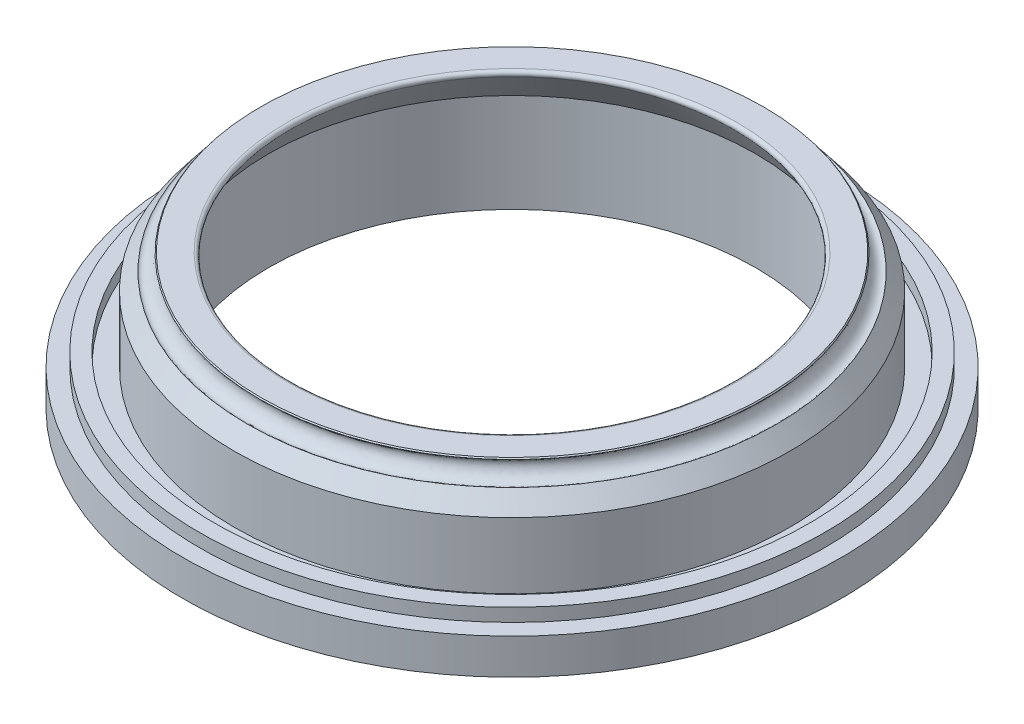
from build123d import *

# Parameters (mm, degrees)
SKETCH2_R          = 2.35
CUT_EXTRUDE2_DEPTH = 5
FILLET1_R          = 1


with BuildPart() as part:
    # Sketch1 → Revolve1 (revolve)
    with BuildSketch(Plane.XY):
        with BuildLine():
            Line((76.326451616, 40.74810371), (66.326451616, 40.74810371))
            Line((66.326451616, 40.74810371), (73.87218168, 29.674663888))
            Line((73.87218168, 29.674663888), (73.87218168, -0.262378674))
            Line((73.87218168, -0.262378674), (75.701423587, -0.262378674))
            add(Edge.make_bspline(
                [(81.701423587, -0.262378674), (81.701423587, 1.737621326), (78.701423587, 1.737621326), (75.701423587, 1.737621326), (75.701423587, -0.262378674)],
                knots=[3.141592654, 3.141592654, 3.141592654, 4.71238898, 4.71238898, 6.283185307, 6.283185307, 6.283185307], degree=2, weights=[1, 0.707106781, 1, 0.707106781, 1]))
            Line((81.701423587, -0.262378674), (100, -0.262378674))
            Line((100, -0.262378674), (100, 10.525760657))
            Line((100, 10.525760657), (94.9, 10.525760657))
            Line((94.9, 10.525760657), (94.9, 14.525760657))
            Line((94.9, 14.525760657), (90.15, 14.525760657))
            Line((90.15, 14.525760657), (90.15, 10.525760657))
            Line((90.15, 10.525760657), (84.25, 10.525760657))
            Line((84.25, 10.525760657), (84.25, 30.525760657))
            Line((84.25, 30.525760657), (80.274489318, 35.65465393))
            add(Edge.make_bspline(
                [(76.598702117, 40.396867385), (75.017964298, 39.171604984), (76.855857899, 36.800498257), (78.6937515, 34.42939153), (80.274489318, 35.65465393)],
                knots=[3.141592654, 3.141592654, 3.141592654, 4.71238898, 4.71238898, 6.283185307, 6.283185307, 6.283185307], degree=2, weights=[1, 0.707106781, 1, 0.707106781, 1]))
            Line((76.598702117, 40.396867385), (76.326451616, 40.74810371))
        make_face()
    revolve(axis=Axis((0, 0, 0), (0, 1, 0)))

    # Sketch2 → Cut-Extrude2 (cut)
    with BuildSketch(Plane.XZ.offset(0.262378674)):
        with Locations((0, 85)):
            Circle(SKETCH2_R)
        with Locations((42.5, 73.612159322)):
            Circle(SKETCH2_R)
        with Locations((73.612159322, 42.5)):
            Circle(SKETCH2_R)
        with Locations((85, 0)):
            Circle(SKETCH2_R)
        with Locations((73.612159322, -42.5)):
            Circle(SKETCH2_R)
        with Locations((42.5, -73.612159322)):
            Circle(SKETCH2_R)
        with Locations((0, -85)):
            Circle(SKETCH2_R)
        with Locations((-42.5, -73.612159322)):
            Circle(SKETCH2_R)
        with Locations((-73.612159322, -42.5)):
            Circle(SKETCH2_R)
        with Locations((-85, 0)):
            Circle(SKETCH2_R)
        with Locations((-73.612159322, 42.5)):
            Circle(SKETCH2_R)
        with Locations((-42.5, 73.612159322)):
            Circle(SKETCH2_R)
    extrude(amount=-CUT_EXTRUDE2_DEPTH, mode=Mode.SUBTRACT)

    # Fillet1
    fillet1_edges = [part.edges().sort_by_distance(p)[0] for p in [
        (-66.326451616, 40.74810371, 0),
    ]]
    fillet(fillet1_edges, radius=FILLET1_R)


solid = part.part
